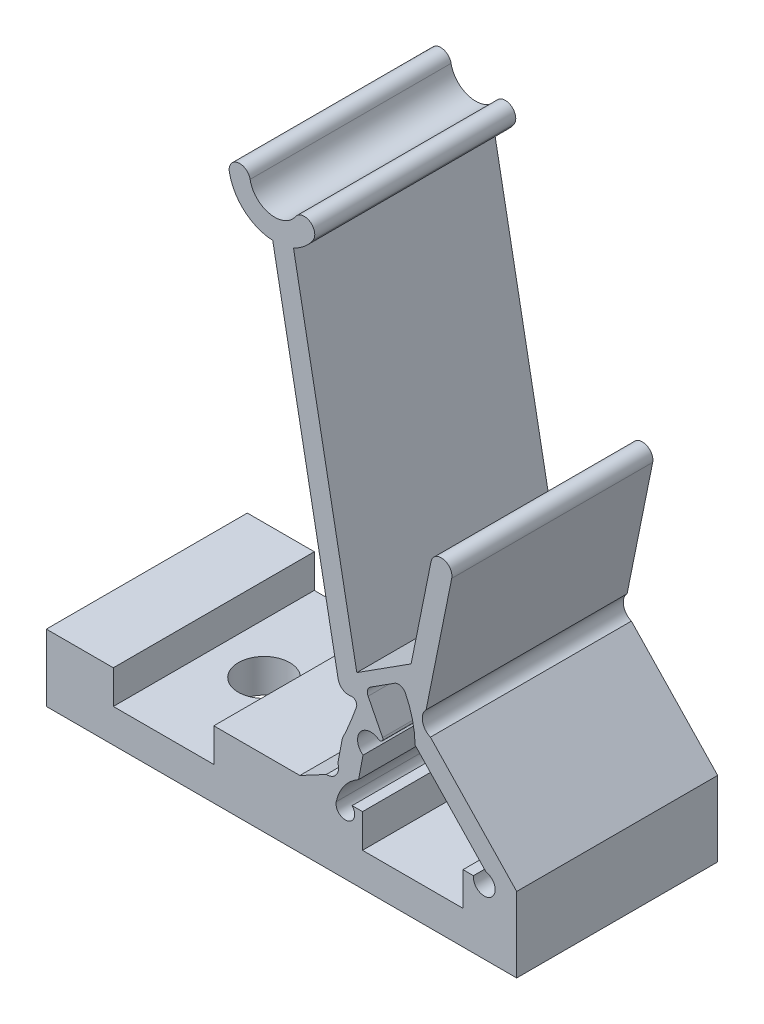
from build123d import *

# Parameters (mm, degrees)
BOSS_CONFIGUP_DEPTH       = 9.525
SKETCH2_W                 = 4.7625
SKETCH2_H                 = 9.525
CUT_NUTSLOT_DEPTH         = 1.5875
F_2_CLEARANCE_HOLE1_D     = 2.4384
F_2_CLEARANCE_HOLE1_DEPTH = 1.5875


with BuildPart() as part:
    # Sketch-ConfigUp → Boss-ConfigUp (new body)
    with BuildSketch(Plane.XY):
        with BuildLine():
            Line((7.315587682, 2.213714366), (7.104153068, 1.103671392))
            ThreePointArc((7.104153068, 1.103671392), (7.02887285, 0.587148983), (6.557966762, 0.361960248))
            Line((6.557966762, 0.361960248), (5.304651863, -0.305823275))
            Line((5.304651863, -0.305823275), (-6.711147083, -0.305823275))
            Line((-6.711147083, -0.305823275), (-6.711147083, -3.480823275))
            Line((-6.711147083, -3.480823275), (15.578632688, -3.480823275))
            Line((15.578632688, -3.480823275), (15.578632688, 0.0709065))
            Line((15.578632688, 0.0709065), (11.489555896, 4.360169677))
            ThreePointArc((11.489555896, 4.360169677), (11.115827658, 4.815287007), (11.286259089, 5.378987021))
            Line((11.286259089, 5.378987021), (12.499382227, 11.378887869))
            ThreePointArc((12.499382227, 11.378887869), (12.108389527, 11.968060772), (11.519216625, 11.577068073))
            Line((11.519216625, 11.577068073), (10.575379996, 6.90901253))
            Line((10.575379996, 6.90901253), (8.002147984, 5.265295329))
            Line((8.002147984, 5.265295329), (5.000864154, 21.195713966))
            ThreePointArc((5.000864154, 21.195713966), (5.515878545, 21.515221814), (5.923633344, 21.963620199))
            ThreePointArc((5.923633344, 21.963620199), (5.792717863, 22.658502302), (5.09783576, 22.527586821))
            ThreePointArc((5.09783576, 22.527586821), (3.870546529, 22.033736006), (2.944624614, 22.978614881))
            ThreePointArc((2.944624614, 22.978614881), (2.360697542, 23.377399504), (1.96191292, 22.793472432))
            ThreePointArc((1.96191292, 22.793472432), (2.679570384, 21.54396233), (4.01815246, 21.010571517))
            Line((4.01815246, 21.010571517), (7.116284258, 4.566096638))
            ThreePointArc((7.116284258, 4.566096638), (7.329390516, 4.240581461), (7.710370279, 4.161658542))
            ThreePointArc((7.710370279, 4.161658542), (7.941736771, 4.080744656), (7.986384484, 3.83973824))
            ThreePointArc((7.986384484, 3.83973824), (7.67084838, 3.018532349), (7.315587682, 2.213714366))
        make_face()
        with BuildLine():
            Line((13.528041298, -0.305823275), (7.778926955, -0.305823275))
            ThreePointArc((7.778926955, -0.305823275), (7.581920737, -1.036684597), (7.028198014, -0.520582992))
            ThreePointArc((7.028198014, -0.520582992), (7.40177857, 0.312546128), (8.086491983, 0.916561115))
            Line((8.086491983, 0.916561115), (8.297926597, 2.026604089))
            ThreePointArc((8.297926597, 2.026604089), (8.15636952, 2.899078498), (9.028843929, 3.040635574))
            ThreePointArc((9.028843929, 3.040635574), (9.1929804, 3.047421198), (9.225253016, 3.208496658))
            Line((9.225253016, 3.208496658), (8.538827812, 4.566096638))
            ThreePointArc((8.538827812, 4.566096638), (8.51473614, 4.804983129), (8.657105129, 4.998317646))
            Line((8.657105129, 4.998317646), (9.788823733, 5.721231603))
            ThreePointArc((9.788823733, 5.721231603), (10.079629218, 5.764709454), (10.306093487, 5.577167225))
            ThreePointArc((10.306093487, 5.577167225), (10.642479335, 4.649344509), (10.765760559, 3.670154961))
            Line((10.765760559, 3.670154961), (13.32194446, 0.988829556))
            Line((13.32194446, 0.988829556), (14.12753679, 0.143798344))
            ThreePointArc((14.12753679, 0.143798344), (14.352707563, -0.780903824), (13.528041298, -0.305823275))
        make_face(mode=Mode.SUBTRACT)
    extrude(amount=BOSS_CONFIGUP_DEPTH)

    # Sketch2 → Cut-NutSlot (cut)
    with BuildSketch(Plane(origin=(0.004306068, -0.305823275, 0), x_dir=(-1, 0, 0), z_dir=(0, -1, 0))):
        with Locations((-10.649178058, -4.7625)):
            Rectangle(SKETCH2_W, SKETCH2_H)
        with Locations((1.159203152, -4.7625)):
            Rectangle(SKETCH2_W, SKETCH2_H)
    extrude(amount=CUT_NUTSLOT_DEPTH, mode=Mode.SUBTRACT)

    # #2 Clearance Hole1
    with Locations(Plane(origin=(0, -3.480823275, 0), x_dir=(-1, 0, 0), z_dir=(0, -1, 0))):
        with Locations((-10.653484126, -4.7625), (1.154897083, -4.7625)):
            Hole(F_2_CLEARANCE_HOLE1_D / 2, depth=F_2_CLEARANCE_HOLE1_DEPTH)


solid = part.part
